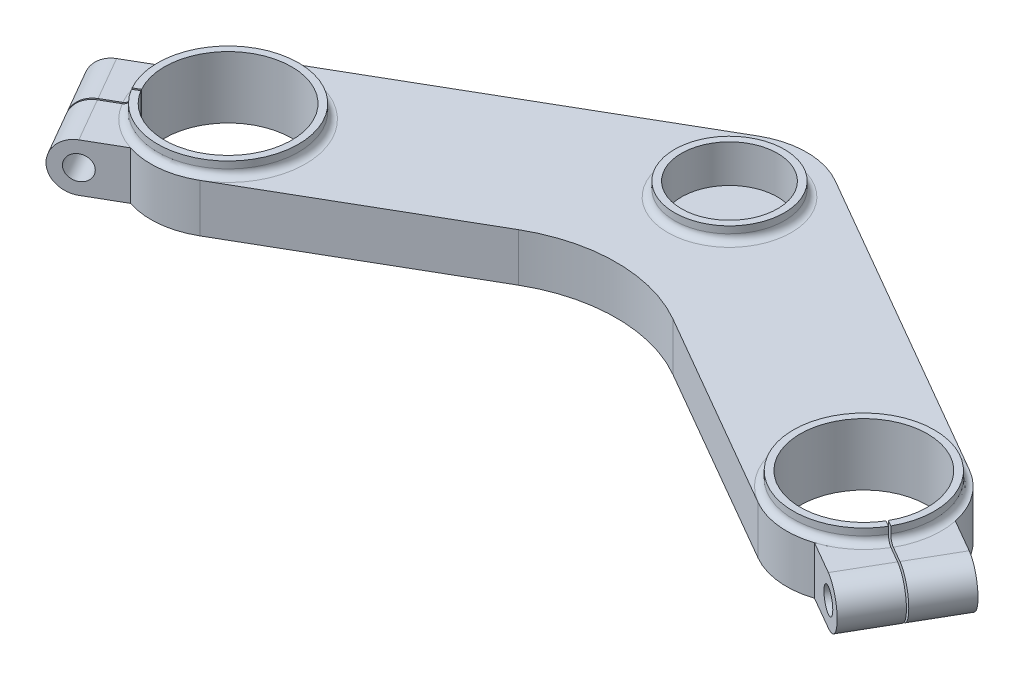
from build123d import *

# Parameters (mm, degrees)
BOSS_EXTRUDE1_DEPTH = 14
FILLET2_R           = 45
SKETCH2_R           = 18.51
CUT_EXTRUDE1_DEPTH  = 15
SKETCH3_R           = 13.985
CUT_EXTRUDE2_DEPTH  = 7
BOSS_EXTRUDE2_DEPTH = 14
CUT_EXTRUDE3_DEPTH  = 101.407669397
CUT_EXTRUDE4_DEPTH  = 101.407669397
SKETCH9_R           = 20.51
SKETCH9_R_2         = 18.51
SKETCH9_R_3         = 15.985
SKETCH9_R_4         = 13.985
BOSS_EXTRUDE3_DEPTH = 4
FILLET5_R           = 2
SKETCH10_R          = 3.5
CUT_EXTRUDE5_DEPTH  = 42
SKETCH11_R          = 3.5
CUT_EXTRUDE6_DEPTH  = 42
CUT_EXTRUDE7_DEPTH  = 42


with BuildPart() as part:
    # Sketch1 → Boss-Extrude1 (new body)
    with BuildSketch(Plane(origin=(0, 0, 0), x_dir=(1, 0, 0), z_dir=(0, 1, 0))):
        with BuildLine():
            Line((-103.75, -33.919328315), (-11.25, 19.485571585))
            ThreePointArc((-11.25, 19.485571585), (0, 22.5), (11.25, 19.485571585))
            Line((11.25, 19.485571585), (103.75, -33.919328315))
            ThreePointArc((103.75, -33.919328315), (111.985571585, -64.6548999), (81.25, -72.890471485))
            Line((81.25, -72.890471485), (0, -25.980762114))
            Line((0, -25.980762114), (-81.25, -72.890471485))
            ThreePointArc((-81.25, -72.890471485), (-111.985571585, -64.6548999), (-103.75, -33.919328315))
        make_face()
    extrude(amount=BOSS_EXTRUDE1_DEPTH)

    # Fillet2
    fillet2_edges = [part.edges().sort_by_distance(p)[0] for p in [
        (0, 7, 25.980762114),
    ]]
    fillet(fillet2_edges, radius=FILLET2_R)

    # Sketch2 → Cut-Extrude1 (cut, through all)
    with BuildSketch(Plane(origin=(0, 14, 0), x_dir=(1, 0, 0), z_dir=(0, 1, 0))):
        with Locations((-92.5, -53.4048999)):
            Circle(SKETCH2_R)
        with Locations((92.5, -53.4048999)):
            Circle(SKETCH2_R)
    extrude(amount=-CUT_EXTRUDE1_DEPTH, mode=Mode.SUBTRACT)

    # Sketch3 → Cut-Extrude2 (cut)
    with BuildSketch(Plane(origin=(0, 14, 0), x_dir=(1, 0, 0), z_dir=(0, 1, 0))):
        Circle(SKETCH3_R)
    extrude(amount=-CUT_EXTRUDE2_DEPTH, mode=Mode.SUBTRACT)

    # Sketch4 → Boss-Extrude2 (add)
    with BuildSketch(Plane(origin=(0, 14, 0), x_dir=(1, 0, 0), z_dir=(0, 1, 0))):
        with BuildLine():
            Line((-114.523687548, -48.799773759), (-131.844195624, -58.799773759))
            Line((-131.844195624, -58.799773759), (-116.844195624, -84.780535872))
            Line((-116.844195624, -84.780535872), (-99.523687548, -74.780535872))
            ThreePointArc((-99.523687548, -74.780535872), (-111.985571585, -64.6548999), (-114.523687548, -48.799773759))
        make_face()
        with BuildLine():
            Line((114.523687548, -48.799773759), (131.844195624, -58.799773759))
            Line((131.844195624, -58.799773759), (116.844195624, -84.780535872))
            Line((116.844195624, -84.780535872), (99.523687548, -74.780535872))
            ThreePointArc((99.523687548, -74.780535872), (111.985571585, -64.6548999), (114.523687548, -48.799773759))
        make_face()
    extrude(amount=-BOSS_EXTRUDE2_DEPTH)

    # Sketch5 → Cut-Extrude3 (cut, through all)
    with BuildSketch(Plane(origin=(7.5, 0, 12.990381057), x_dir=(0.866025404, 0, -0.5), z_dir=(0.5, 0, 0.866025404))):
        with BuildLine():
            Line((-143.580309631, 0), (-143.580309631, 14))
            Line((-143.580309631, 14), (-134.580309631, 14))
            ThreePointArc((-134.580309631, 14), (-141.580309631, 7), (-134.580309631, 0))
            Line((-134.580309631, 0), (-143.580309631, 0))
        make_face()
    extrude(amount=-CUT_EXTRUDE3_DEPTH, mode=Mode.SUBTRACT)

    # Sketch6 → Cut-Extrude4 (cut, through all)
    with BuildSketch(Plane(origin=(-7.5, 0, 12.990381057), x_dir=(0.866025404, 0, 0.5), z_dir=(-0.5, 0, 0.866025404))):
        with BuildLine():
            Line((134.580309631, 14), (143.580309631, 14))
            Line((143.580309631, 14), (143.580309631, 0))
            Line((143.580309631, 0), (134.580309631, 0))
            ThreePointArc((134.580309631, 0), (141.580309631, 7), (134.580309631, 14))
        make_face()
    extrude(amount=-CUT_EXTRUDE4_DEPTH, mode=Mode.SUBTRACT)

    # Sketch9 → Boss-Extrude3 (add)
    with BuildSketch(Plane(origin=(0, 14, 0), x_dir=(1, 0, 0), z_dir=(0, 1, 0))):
        with Locations((-92.5, -53.4048999)):
            Circle(SKETCH9_R)
        with Locations((-92.5, -53.4048999)):
            Circle(SKETCH9_R_2, mode=Mode.SUBTRACT)
        Circle(SKETCH9_R_3)
        Circle(SKETCH9_R_4, mode=Mode.SUBTRACT)
        with Locations((92.5, -53.4048999)):
            Circle(SKETCH9_R)
        with Locations((92.5, -53.4048999)):
            Circle(SKETCH9_R_2, mode=Mode.SUBTRACT)
    extrude(amount=BOSS_EXTRUDE3_DEPTH)

    # Fillet5
    fillet5_edges = [part.edges().sort_by_distance(p)[0] for p in [
        (-113.01, 14, 53.4048999),
        (-15.985, 14, 0),
        (71.99, 14, 53.4048999),
    ]]
    fillet(fillet5_edges, radius=FILLET5_R)

    # Sketch10 → Cut-Extrude5 (cut)
    with BuildSketch(Plane(origin=(7.5, 0, 12.990381057), x_dir=(0.866025404, 0, -0.5), z_dir=(0.5, 0, 0.866025404))):
        with Locations((-134.580309631, 7)):
            Circle(SKETCH10_R)
    extrude(amount=-CUT_EXTRUDE5_DEPTH, mode=Mode.SUBTRACT)

    # Sketch11 → Cut-Extrude6 (cut)
    with BuildSketch(Plane(origin=(-7.5, 0, 12.990381057), x_dir=(0.866025404, 0, 0.5), z_dir=(-0.5, 0, 0.866025404))):
        with Locations((134.580309631, 7)):
            Circle(SKETCH11_R)
    extrude(amount=-CUT_EXTRUDE6_DEPTH, mode=Mode.SUBTRACT)

    # Sketch12 → Cut-Extrude7 (cut)
    with BuildSketch(Plane(origin=(0, 18, 0), x_dir=(1, 0, 0), z_dir=(0, 1, 0))):
        Polygon((-92.363302775, -53.614217526), (-129.001019076, -74.767012895), (-129.274413527, -74.348377643), (-92.636697225, -53.195582274), align=None)
        Polygon((129.274413527, -74.348377643), (129.001019076, -74.767012895), (92.363302775, -53.614217526), (92.636697225, -53.195582274), align=None)
    extrude(amount=-CUT_EXTRUDE7_DEPTH, mode=Mode.SUBTRACT)


solid = part.part
